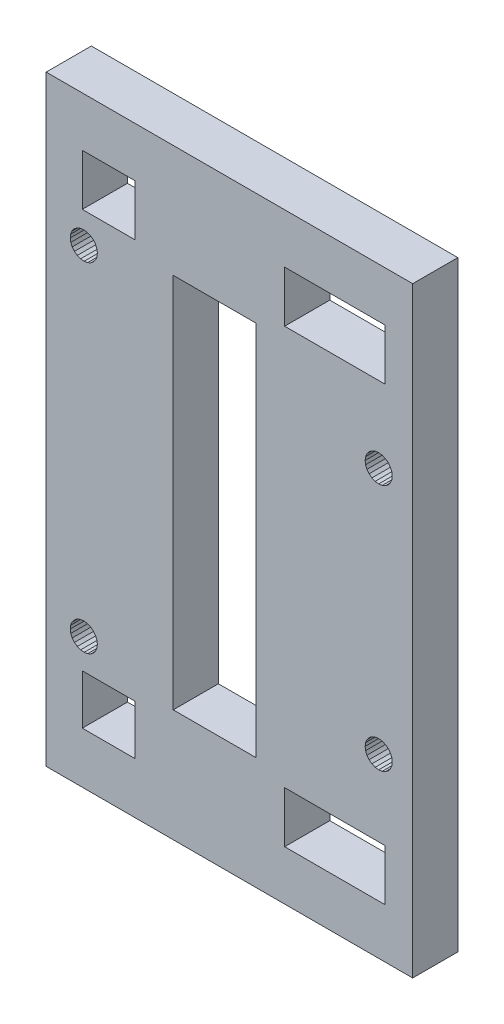
from build123d import *

# Parameters (mm, degrees)
SKETCH1_W           = 48.698269881
SKETCH1_H           = 79.9
SKETCH1_W_2         = 13.312275424
SKETCH1_H_2         = 6.8
SKETCH1_W_3         = 7
SKETCH1_H_3         = 6.6
SKETCH1_W_4         = 10.999995004
SKETCH1_H_4         = 49.999979698
BOSS_EXTRUDE1_DEPTH = 6


with BuildPart() as part:
    # Sketch1 → Boss-Extrude1 (new body)
    with BuildSketch(Plane.XY):
        with Locations((-328.119749272, -326.315940756)):
            Rectangle(SKETCH1_W, SKETCH1_H)
        Polygon((-306.547681314, -310.331815037), (-306.727502074, -310.765940756), (-307.013555595, -311.138732962), (-307.386347801, -311.424786483), (-307.82047352, -311.604607243), (-308.286347801, -311.665940756), (-308.752222082, -311.604607243), (-309.186347801, -311.424786483), (-309.559140007, -311.138732962), (-309.845193528, -310.765940756), (-310.025014288, -310.331815037), (-310.086347801, -309.865940756), (-310.025014288, -309.400066475), (-309.845193528, -308.965940756), (-309.559140007, -308.59314855), (-309.186347801, -308.307095029), (-308.752222082, -308.127274269), (-308.286347801, -308.065940756), (-307.82047352, -308.127274269), (-307.386347801, -308.307095029), (-307.013555595, -308.59314855), (-306.727502074, -308.965940756), (-306.547681314, -309.400066475), (-306.486347801, -309.865940756), align=None, mode=Mode.SUBTRACT)
        with Locations((-314.125021924, -356.265940756)):
            Rectangle(SKETCH1_W_2, SKETCH1_H_2, mode=Mode.SUBTRACT)
        with Locations((-344.168884212, -356.165940756)):
            Rectangle(SKETCH1_W_3, SKETCH1_H_3, mode=Mode.SUBTRACT)
        with Locations((-314.125021924, -296.365940756)):
            Rectangle(SKETCH1_W_2, SKETCH1_H_2, mode=Mode.SUBTRACT)
        Polygon((-349.005509995, -349.753374061), (-349.195776334, -349.323723778), (-349.268357829, -348.859468921), (-349.218308171, -348.392247692), (-349.04903816, -347.953900444), (-348.77208327, -347.574299819), (-348.406317517, -347.279314973), (-347.976667234, -347.089048634), (-347.512412377, -347.016467139), (-347.045191148, -347.066516797), (-346.6068439, -347.235786808), (-346.227243275, -347.512741698), (-345.932258429, -347.878507451), (-345.74199209, -348.308157734), (-345.669410595, -348.772412591), (-345.719460253, -349.23963382), (-345.888730263, -349.677981068), (-346.165685154, -350.057581692), (-346.531450907, -350.352566539), (-346.96110119, -350.542832878), (-347.425356047, -350.615414373), (-347.892577276, -350.565364715), (-348.330924524, -350.396094704), (-348.710525148, -350.119139814), align=None, mode=Mode.SUBTRACT)
        Polygon((-307.013555595, -341.49314855), (-306.727502074, -341.865940756), (-306.547681314, -342.300066475), (-306.486347801, -342.765940756), (-306.547681314, -343.231815037), (-306.727502074, -343.665940756), (-307.013555595, -344.038732962), (-307.386347801, -344.324786483), (-307.82047352, -344.504607243), (-308.286347801, -344.565940756), (-308.752222082, -344.504607243), (-309.186347801, -344.324786483), (-309.559140007, -344.038732962), (-309.845193528, -343.665940756), (-310.025014288, -343.231815037), (-310.086347801, -342.765940756), (-310.025014288, -342.300066475), (-309.845193528, -341.865940756), (-309.559140007, -341.49314855), (-309.186347801, -341.207095029), (-308.752222082, -341.027274269), (-308.286347801, -340.965940756), (-307.82047352, -341.027274269), (-307.386347801, -341.207095029), align=None, mode=Mode.SUBTRACT)
        Polygon((-347.042471777, -302.06717764), (-346.604388229, -302.237128957), (-346.225218653, -302.51467369), (-345.93080283, -302.880897622), (-345.741204711, -303.310843199), (-345.669345095, -303.77521034), (-345.720121096, -304.242353191), (-345.890072413, -304.680436739), (-346.167617146, -305.059606315), (-346.533841078, -305.354022138), (-346.963786655, -305.543620257), (-347.428153795, -305.615479873), (-347.895296647, -305.564703872), (-348.333380195, -305.394752555), (-348.712549771, -305.117207822), (-349.006965594, -304.75098389), (-349.196563713, -304.321038313), (-349.268423329, -303.856671172), (-349.217647328, -303.389528321), (-349.047696011, -302.951444773), (-348.770151278, -302.572275197), (-348.403927346, -302.277859374), (-347.973981769, -302.088261255), (-347.509614628, -302.016401639), align=None, mode=Mode.SUBTRACT)
        with Locations((-344.168884212, -296.365940756)):
            Rectangle(SKETCH1_W_3, SKETCH1_H_2, mode=Mode.SUBTRACT)
        with Locations((-330.086347801, -326.315940756)):
            Rectangle(SKETCH1_W_4, SKETCH1_H_4, mode=Mode.SUBTRACT)
    extrude(amount=BOSS_EXTRUDE1_DEPTH)


solid = part.part
